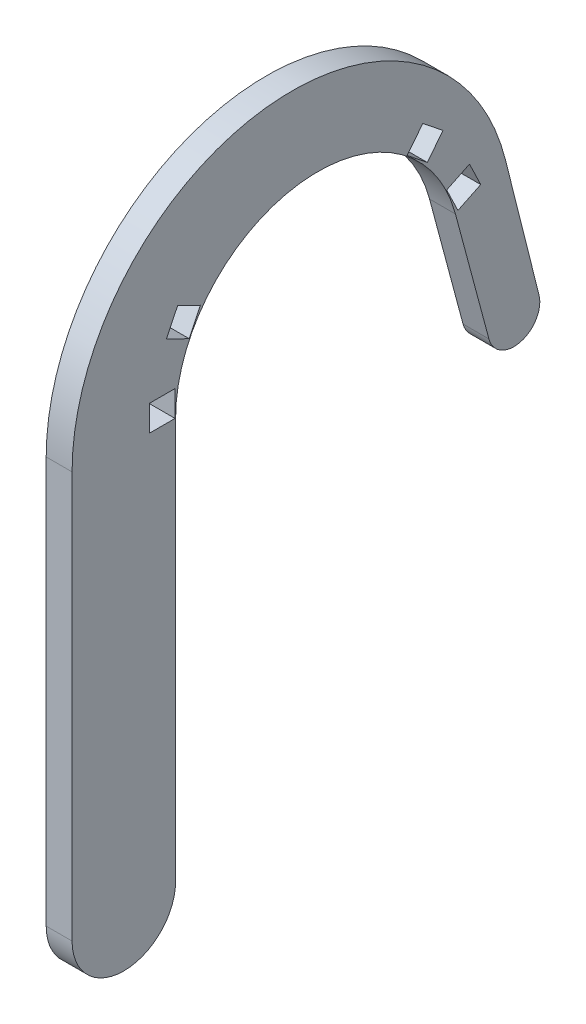
from build123d import *

# Parameters (mm, degrees)
BOSS_EXTRUDE1_DEPTH = 6.35
CUT_EXTRUDE2_START  = -7.35
CUT_EXTRUDE2_DEPTH  = 8.35
CIRPATTERN2_COUNT   = 8
CIRPATTERN2_ANGLE   = 180


with BuildPart() as part:
    # Sketch1 → Boss-Extrude1 (new body)
    with BuildSketch(Plane(origin=(0, 0, 0), x_dir=(0, 0, -1), z_dir=(1, 0, 0))):
        with BuildLine():
            Line((-60.325, -98.425), (-60.325, 1.27))
            ThreePointArc((-60.325, 1.27), (-12.969041148, 54.83761073), (46.001592655, 14.408164693))
            Line((46.001592655, 14.408164693), (54.245104063, -18.439722464))
            ThreePointArc((54.245104063, -18.439722464), (49.680727349, -26.131903505), (41.952464165, -21.628889834))
            Line((41.952464165, -21.628889834), (33.734959483, 9.03925515))
            ThreePointArc((33.734959483, 9.03925515), (-4.558627263, 34.626211783), (-34.925, 0))
            Line((-34.925, 0), (-34.925, -98.425))
            ThreePointArc((-34.925, -98.425), (-47.625, -111.125), (-60.325, -98.425))
        make_face()
    extrude(amount=BOSS_EXTRUDE1_DEPTH)

    # Sketch5 → Cut-Extrude2 (cut)
    with BuildSketch(Plane(origin=(6.35, 0, 0), x_dir=(0, 0, -1), z_dir=(1, 0, 0)).offset(CUT_EXTRUDE2_START)):
        Polygon((-38.1, 6.35), (-41.275, 6.35), (-41.275, 0), (-35.06174314, 0), (-35.06174314, 6.35), align=None)
    cut_extrude2 = extrude(amount=CUT_EXTRUDE2_DEPTH, mode=Mode.SUBTRACT)

    # CirPattern2: Cut-Extrude2 ×8 about axis, 4 skipped
    cirpattern2_axis = Axis((0, 0, 0), (-1, 0, 0))
    add([cut_extrude2.rotate(cirpattern2_axis, i * CIRPATTERN2_ANGLE / (CIRPATTERN2_COUNT - 1)) for i in range(1, CIRPATTERN2_COUNT) if i not in (2, 3, 4, 7)], mode=Mode.SUBTRACT)


solid = part.part
